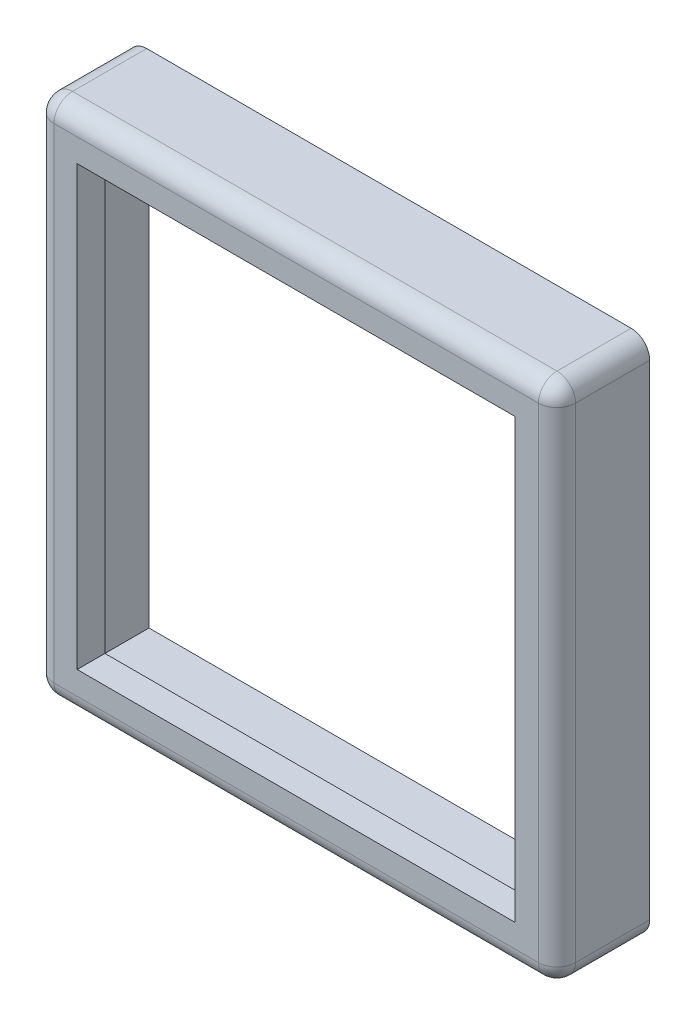
from build123d import *

# Parameters (mm, degrees)
SKETCH1_W           = 14.2875
SKETCH1_H           = 14.2875
SKETCH1_W_2         = 12.0015
SKETCH1_H_2         = 12.0015
BOSS_EXTRUDE1_DEPTH = 2.54
SKETCH2_W           = 13.1445
SKETCH2_H           = 13.1445
CUT_EXTRUDE1_DEPTH  = 1.778
FILLET1_R           = 0.508


with BuildPart() as part:
    # Sketch1 → Boss-Extrude1 (new body)
    with BuildSketch(Plane.XY):
        with Locations((12.7, -106.3625)):
            Rectangle(SKETCH1_W, SKETCH1_H)
        with Locations((12.7, -106.3625)):
            Rectangle(SKETCH1_W_2, SKETCH1_H_2, mode=Mode.SUBTRACT)
    extrude(amount=-BOSS_EXTRUDE1_DEPTH)

    # Sketch2 → Cut-Extrude1 (cut)
    with BuildSketch(Plane(origin=(0, 0, -2.54), x_dir=(-1, 0, 0), z_dir=(0, 0, -1))):
        with Locations((-12.7, -106.3625)):
            Rectangle(SKETCH2_W, SKETCH2_H)
    extrude(amount=-CUT_EXTRUDE1_DEPTH, mode=Mode.SUBTRACT)

    # Fillet1
    fillet1_edges = [part.edges().sort_by_distance(p)[0] for p in [
        (5.55625, -106.3625, 0),
        (12.7, -99.21875, 0),
        (19.84375, -106.3625, 0),
        (12.7, -113.50625, 0),
        (5.55625, -113.50625, -1.27),
        (5.55625, -99.21875, -1.27),
        (19.84375, -99.21875, -1.27),
        (19.84375, -113.50625, -1.27),
    ]]
    fillet(fillet1_edges, radius=FILLET1_R)


solid = part.part
